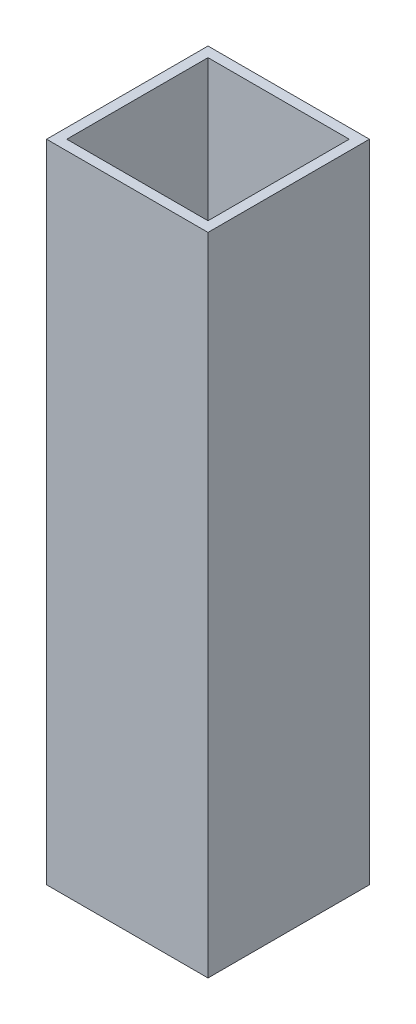
from build123d import *

# Parameters (mm, degrees)
SKETCH1_W           = 25.4
SKETCH1_H           = 25.4
SKETCH1_W_2         = 22.225
SKETCH1_H_2         = 22.225
BOSS_EXTRUDE1_DEPTH = 101.6


with BuildPart() as part:
    # Sketch1 → Boss-Extrude1 (new body)
    with BuildSketch(Plane(origin=(0, 0, 0), x_dir=(1, 0, 0), z_dir=(0, 1, 0))):
        Rectangle(SKETCH1_W, SKETCH1_H)
        Rectangle(SKETCH1_W_2, SKETCH1_H_2, mode=Mode.SUBTRACT)
    extrude(amount=BOSS_EXTRUDE1_DEPTH)


solid = part.part
